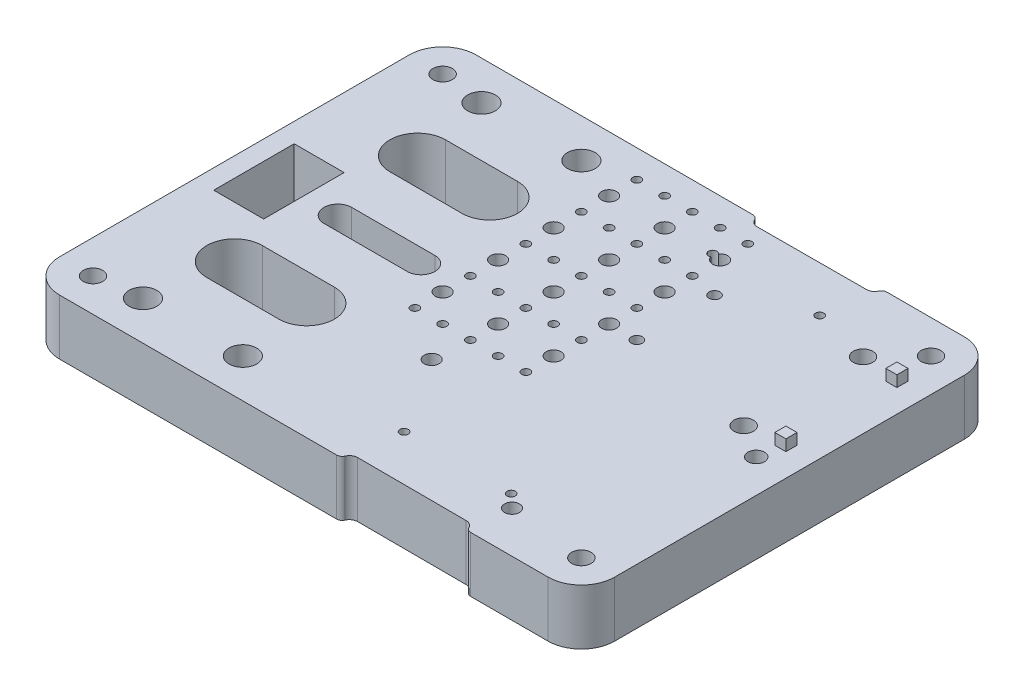
from build123d import *

# Parameters (mm, degrees)
SKETCH_1_W          = 100
SKETCH_1_H          = 75
SKETCH_1_R          = 1.75
SKETCH_1_R_2        = 1.25
SKETCH_1_R_3        = 0.75
SKETCH_1_R_4        = 1.5
SKETCH_1_W_2        = 9
SKETCH_1_H_2        = 14.5
EXTRUDE_1_DEPTH     = 10
FILLET_5_R          = 6
CUT_EXTRUDE_1_REACH = 12
SKETCH_2_R          = 1.35
SKETCH_2_R_2        = 1.75
SKETCH_2_R_3        = 1
SKETCH_3_R          = 2.5
CUT_EXTRUDE_2_DEPTH = 7
SKETCH_4_W          = 2
SKETCH_4_H          = 2
EXTRUDE_2_DEPTH     = 2
CUT_EXTRUDE_3_DEPTH = 36.8
FILLET_6_R          = 1
SKETCH_6_R          = 1.35
SKETCH_6_R_2        = 0.75
CUT_EXTRUDE_4_DEPTH = 36.8


with BuildPart() as part:
    # Эскиз1 → Бобышка-Вытянуть1 (new body)
    with BuildSketch(Plane(origin=(0, 0, 0), x_dir=(1, 0, 0), z_dir=(0, 1, 0))):
        with Locations((50, 37.5)):
            Rectangle(SKETCH_1_W, SKETCH_1_H)
        with Locations((6, 69)):
            Circle(SKETCH_1_R, mode=Mode.SUBTRACT)
        with Locations((94, 69)):
            Circle(SKETCH_1_R, mode=Mode.SUBTRACT)
        with Locations((94, 6)):
            Circle(SKETCH_1_R, mode=Mode.SUBTRACT)
        with Locations((6, 6)):
            Circle(SKETCH_1_R, mode=Mode.SUBTRACT)
        with Locations((14, 68)):
            Circle(SKETCH_1_R_2, mode=Mode.SUBTRACT)
        with Locations((32, 68)):
            Circle(SKETCH_1_R_2, mode=Mode.SUBTRACT)
        with Locations((32, 7)):
            Circle(SKETCH_1_R_2, mode=Mode.SUBTRACT)
        with Locations((14, 7)):
            Circle(SKETCH_1_R_2, mode=Mode.SUBTRACT)
        with Locations((58.35, 65.3)):
            Circle(SKETCH_1_R_3, mode=Mode.SUBTRACT)
        with Locations((77.65, 65.3)):
            Circle(SKETCH_1_R_3, mode=Mode.SUBTRACT)
        with Locations((77.65, 9.7)):
            Circle(SKETCH_1_R_3, mode=Mode.SUBTRACT)
        with Locations((58.35, 9.7)):
            Circle(SKETCH_1_R_3, mode=Mode.SUBTRACT)
        with Locations((94, 37.5)):
            Circle(SKETCH_1_R_4, mode=Mode.SUBTRACT)
        with BuildLine():
            Line((16.5, 59), (29.5, 59))
            ThreePointArc((29.5, 59), (34.5, 54), (29.5, 49))
            Line((29.5, 49), (16.5, 49))
            ThreePointArc((16.5, 49), (11.5, 54), (16.5, 59))
        make_face(mode=Mode.SUBTRACT)
        with BuildLine():
            Line((16.5, 16), (29.5, 16))
            ThreePointArc((29.5, 16), (34.5, 21), (29.5, 26))
            Line((29.5, 26), (16.5, 26))
            ThreePointArc((16.5, 26), (11.5, 21), (16.5, 16))
        make_face(mode=Mode.SUBTRACT)
        with Locations((8, 37.5)):
            Rectangle(SKETCH_1_W_2, SKETCH_1_H_2, mode=Mode.SUBTRACT)
    extrude(amount=EXTRUDE_1_DEPTH)

    # Скругление5
    fillet_5_edges = [part.edges().sort_by_distance(p)[0] for p in [
        (0, 5, -75),
        (100, 5, -75),
        (100, 5, 0),
        (0, 5, 0),
    ]]
    fillet(fillet_5_edges, radius=FILLET_5_R)

    # Эскиз2 → Вырез-Вытянуть1 (cut, up to next)
    with BuildSketch(Plane.XZ, mode=Mode.PRIVATE) as cut_extrude_1_sk1:
        with Locations((80, -7.5)):
            Circle(SKETCH_2_R)
    cut_extrude_1_tool1 = extrude(cut_extrude_1_sk1.sketch, amount=-CUT_EXTRUDE_1_REACH, mode=Mode.PRIVATE) & part.part
    add(cut_extrude_1_tool1.solids().sort_by_distance((80, 0, -7.5))[0], mode=Mode.SUBTRACT)
    # Эскиз2 → Вырез-Вытянуть1 (cut, up to next)
    with BuildSketch(Plane.XZ, mode=Mode.PRIVATE) as cut_extrude_1_sk2:
        with Locations((88, -62.75)):
            Circle(SKETCH_2_R_2)
    cut_extrude_1_tool2 = extrude(cut_extrude_1_sk2.sketch, amount=-CUT_EXTRUDE_1_REACH, mode=Mode.PRIVATE) & part.part
    add(cut_extrude_1_tool2.solids().sort_by_distance((88, 0, -62.75))[0], mode=Mode.SUBTRACT)
    # Эскиз2 → Вырез-Вытянуть1 (cut, up to next)
    with BuildSketch(Plane.XZ, mode=Mode.PRIVATE) as cut_extrude_1_sk3:
        with Locations((88, -41.25)):
            Circle(SKETCH_2_R_2)
    cut_extrude_1_tool3 = extrude(cut_extrude_1_sk3.sketch, amount=-CUT_EXTRUDE_1_REACH, mode=Mode.PRIVATE) & part.part
    add(cut_extrude_1_tool3.solids().sort_by_distance((88, 0, -41.25))[0], mode=Mode.SUBTRACT)
    # Эскиз2 → Вырез-Вытянуть1 (cut, up to next)
    with BuildSketch(Plane.XZ, mode=Mode.PRIVATE) as cut_extrude_1_sk4:
        with Locations((49.550909155, -23.473456754)):
            Circle(SKETCH_2_R)
    cut_extrude_1_tool4 = extrude(cut_extrude_1_sk4.sketch, amount=-CUT_EXTRUDE_1_REACH, mode=Mode.PRIVATE) & part.part
    add(cut_extrude_1_tool4.solids().sort_by_distance((49.550909, 0, -23.473457))[0], mode=Mode.SUBTRACT)
    # Эскиз2 → Вырез-Вытянуть1 (cut, up to next)
    with BuildSketch(Plane.XZ, mode=Mode.PRIVATE) as cut_extrude_1_sk5:
        with Locations((65, -59)):
            Circle(SKETCH_2_R_3)
    cut_extrude_1_tool5 = extrude(cut_extrude_1_sk5.sketch, amount=-CUT_EXTRUDE_1_REACH, mode=Mode.PRIVATE) & part.part
    add(cut_extrude_1_tool5.solids().sort_by_distance((65, 0, -59))[0], mode=Mode.SUBTRACT)
    # Эскиз2 → Вырез-Вытянуть1 (cut, up to next)
    with BuildSketch(Plane.XZ, mode=Mode.PRIVATE) as cut_extrude_1_sk6:
        with Locations((65, -45)):
            Circle(SKETCH_2_R_3)
    cut_extrude_1_tool6 = extrude(cut_extrude_1_sk6.sketch, amount=-CUT_EXTRUDE_1_REACH, mode=Mode.PRIVATE) & part.part
    add(cut_extrude_1_tool6.solids().sort_by_distance((65, 0, -45))[0], mode=Mode.SUBTRACT)
    # Эскиз2 → Вырез-Вытянуть1 (cut, up to next)
    with BuildSketch(Plane.XZ, mode=Mode.PRIVATE) as cut_extrude_1_sk7:
        with BuildLine():
            Line((18.612528652, -35), (33.612528652, -35))
            ThreePointArc((33.612528652, -35), (36.112528652, -37.5), (33.612528652, -40))
            Line((33.612528652, -40), (18.612528652, -40))
            ThreePointArc((18.612528652, -40), (16.112528652, -37.5), (18.612528652, -35))
        make_face()
    cut_extrude_1_tool7 = extrude(cut_extrude_1_sk7.sketch, amount=-CUT_EXTRUDE_1_REACH, mode=Mode.PRIVATE) & part.part
    add(cut_extrude_1_tool7.solids().sort_by_distance((26.112529, 0, -37.5))[0], mode=Mode.SUBTRACT)

    # Эскиз3 → Вырез-Вытянуть2 (cut)
    with BuildSketch(Plane(origin=(0, 10, 0), x_dir=(1, 0, 0), z_dir=(0, 1, 0))):
        with Locations((14, 68)):
            Circle(SKETCH_3_R)
        with Locations((32, 68)):
            Circle(SKETCH_3_R)
        with Locations((14, 7)):
            Circle(SKETCH_3_R)
        with Locations((32, 7)):
            Circle(SKETCH_3_R)
    extrude(amount=-CUT_EXTRUDE_2_DEPTH, mode=Mode.SUBTRACT)

    # Эскиз4 → Бобышка-Вытянуть2 (add)
    with BuildSketch(Plane(origin=(0, 10, 0), x_dir=(1, 0, 0), z_dir=(0, 1, 0))):
        with Locations((94.855745834, 42)):
            Rectangle(SKETCH_4_W, SKETCH_4_H)
        with Locations((94.855745834, 62)):
            Rectangle(SKETCH_4_W, SKETCH_4_H)
    extrude(amount=EXTRUDE_2_DEPTH)

    # Эскиз5 → Вырез-Вытянуть3 (cut)
    with BuildSketch(Plane(origin=(0, 10, 0), x_dir=(1, 0, 0), z_dir=(0, 1, 0))):
        with BuildLine():
            Line((58.204642338, 1.499992816), (77.804642338, 1.439332644))
            ThreePointArc((77.804642338, 1.439332644), (79.299992816, -0.06530251), (77.795357662, -1.560652988))
            Line((77.795357662, -1.560652988), (58.195357662, -1.499992816))
            ThreePointArc((58.195357662, -1.499992816), (56.700007184, 0.004642338), (58.204642338, 1.499992816))
        make_face()
        with BuildLine():
            Line((58.204642338, 73.500007184), (77.804642338, 73.560667356))
            ThreePointArc((77.804642338, 73.560667356), (79.299992816, 75.06530251), (77.795357662, 76.560652988))
            Line((77.795357662, 76.560652988), (58.195357662, 76.499992816))
            ThreePointArc((58.195357662, 76.499992816), (56.700007184, 74.995357662), (58.204642338, 73.500007184))
        make_face()
    extrude(amount=-CUT_EXTRUDE_3_DEPTH, mode=Mode.SUBTRACT)

    # Скругление6
    fillet_6_edges = [part.edges().sort_by_distance(p)[0] for p in [
        (79.298772946, 5, -75),
        (56.7, 5, -75),
        (79.298772946, 5, 0),
        (56.7, 5, 0),
    ]]
    fillet(fillet_6_edges, radius=FILLET_6_R)

    # Эскиз6 → Вырез-Вытянуть4 (cut)
    with BuildSketch(Plane(origin=(0, 10, 0), x_dir=(1, 0, 0), z_dir=(0, 1, 0))):
        with Locations((40, 65)):
            Circle(SKETCH_6_R)
        with Locations((50, 65)):
            Circle(SKETCH_6_R)
        with Locations((60, 65)):
            Circle(SKETCH_6_R)
        with Locations((50, 55)):
            Circle(SKETCH_6_R)
        with Locations((60, 55)):
            Circle(SKETCH_6_R)
        with Locations((50, 45)):
            Circle(SKETCH_6_R)
        with Locations((60, 45)):
            Circle(SKETCH_6_R)
        with Locations((50, 35)):
            Circle(SKETCH_6_R)
        with Locations((60, 35)):
            Circle(SKETCH_6_R)
        with Locations((40, 55)):
            Circle(SKETCH_6_R)
        with Locations((40, 45)):
            Circle(SKETCH_6_R)
        with Locations((40, 35)):
            Circle(SKETCH_6_R)
        with Locations((40, 70)):
            Circle(SKETCH_6_R_2)
        with Locations((45, 70)):
            Circle(SKETCH_6_R_2)
        with Locations((50, 70)):
            Circle(SKETCH_6_R_2)
        with Locations((55, 70)):
            Circle(SKETCH_6_R_2)
        with Locations((60, 70)):
            Circle(SKETCH_6_R_2)
        with Locations((45, 60)):
            Circle(SKETCH_6_R_2)
        with Locations((50, 60)):
            Circle(SKETCH_6_R_2)
        with Locations((55, 60)):
            Circle(SKETCH_6_R_2)
        with Locations((60, 60)):
            Circle(SKETCH_6_R_2)
        with Locations((45, 50)):
            Circle(SKETCH_6_R_2)
        with Locations((50, 50)):
            Circle(SKETCH_6_R_2)
        with Locations((55, 50)):
            Circle(SKETCH_6_R_2)
        with Locations((60, 50)):
            Circle(SKETCH_6_R_2)
        with Locations((45, 40)):
            Circle(SKETCH_6_R_2)
        with Locations((50, 40)):
            Circle(SKETCH_6_R_2)
        with Locations((55, 40)):
            Circle(SKETCH_6_R_2)
        with Locations((60, 40)):
            Circle(SKETCH_6_R_2)
        with Locations((45, 30)):
            Circle(SKETCH_6_R_2)
        with Locations((50, 30)):
            Circle(SKETCH_6_R_2)
        with Locations((55, 30)):
            Circle(SKETCH_6_R_2)
        with Locations((60, 30)):
            Circle(SKETCH_6_R_2)
        with Locations((40, 60)):
            Circle(SKETCH_6_R_2)
        with Locations((40, 50)):
            Circle(SKETCH_6_R_2)
        with Locations((40, 40)):
            Circle(SKETCH_6_R_2)
        with Locations((40, 30)):
            Circle(SKETCH_6_R_2)
    extrude(amount=-CUT_EXTRUDE_4_DEPTH, mode=Mode.SUBTRACT)


solid = part.part
